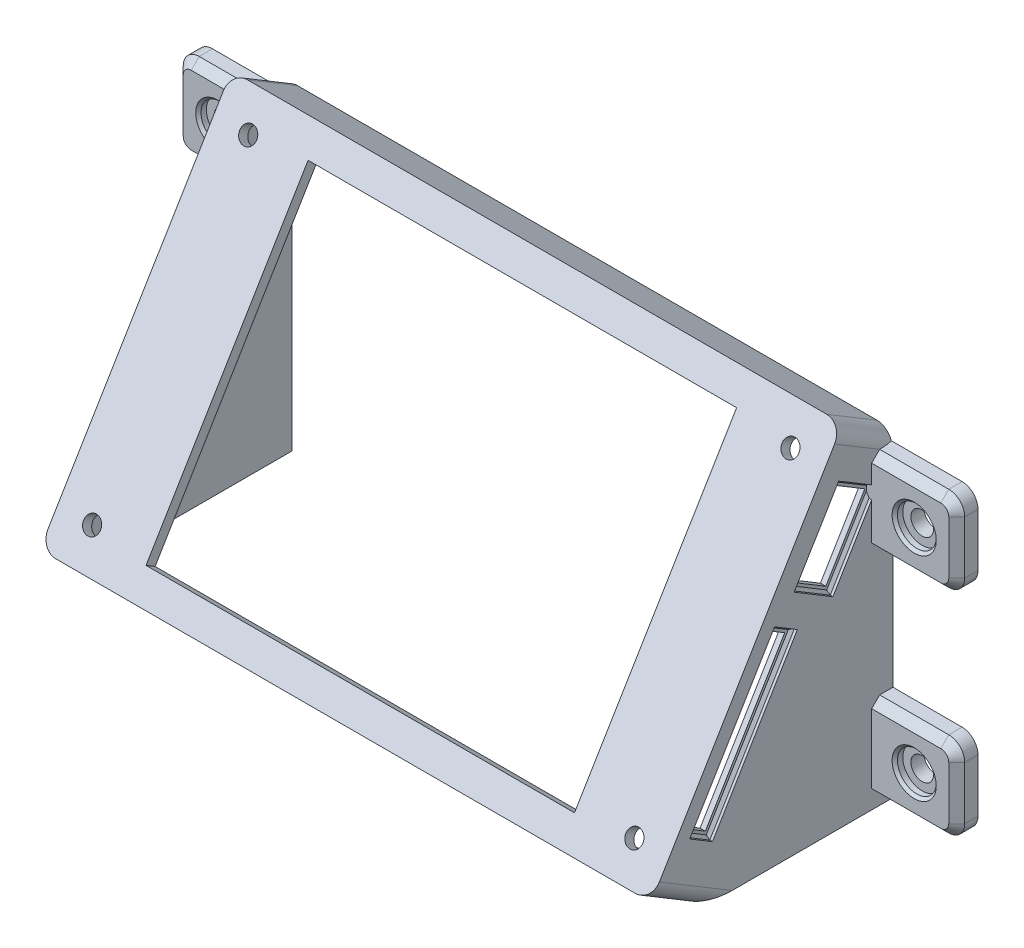
from build123d import *

# Parameters (mm, degrees)
BOSS_EXTRUDE1_DEPTH      = 115
SKETCH2_W                = 115
SKETCH2_H                = 70
BOSS_EXTRUDE2_DEPTH      = 11
FILLET1_R                = 3
SHELL1_T                 = -2
SKETCH3_R                = 1.6
CUT_EXTRUDE1_DEPTH       = 2
SKETCH4_W                = 80.6
SKETCH4_H                = 59.2
CUT_EXTRUDE2_DEPTH       = 2
CUT_EXTRUDE3_DEPTH       = 2
CUT_EXTRUDE4_DEPTH       = 1
CHAMFER3_SIZE            = 0.5
BOSS_EXTRUDE3_START      = -2
SKETCH7_W                = 4
SKETCH7_H                = 16
BOSS_EXTRUDE3_DEPTH      = 18
SKETCH8_R                = 2.125
CUT_EXTRUDE5_DEPTH       = 4
SKETCH9_R                = 3.65
CUT_EXTRUDE6_DEPTH       = 1.5
CHAMFER4_SIZE            = 0.5
FILLET2_R                = 3
CHAMFER4_OF_MIRROR1_SIZE = 0.5
FILLET2_OF_MIRROR1_R     = 3
CHAMFER5_SIZE            = 1.5


with BuildPart() as part:
    # Sketch1 → Boss-Extrude1 (new body)
    with BuildSketch(Plane(origin=(0, 0, 0), x_dir=(0, 0, -1), z_dir=(1, 0, 0))):
        Polygon((0, 0), (0, 60), (-36.055512755, 0), align=None)
    extrude(amount=BOSS_EXTRUDE1_DEPTH)

    # Sketch2 → Boss-Extrude2 (add)
    with BuildSketch(Plane(origin=(0, 15.918367347, 26.489764473), x_dir=(1, 0, 0), z_dir=(0, 0.515078754, 0.857142857))):
        with Locations((57.5, 16.428571429)):
            Rectangle(SKETCH2_W, SKETCH2_H)
    extrude(amount=BOSS_EXTRUDE2_DEPTH)

    # Fillet1
    fillet1_edges = [part.edges().sort_by_distance(p)[0] for p in [
        (0, 62.832933145, 4.714285714),
        (0, 2.832933145, 40.769798469),
        (115, 2.832933145, 40.769798469),
        (115, 62.832933145, 4.714285714),
    ]]
    fillet(fillet1_edges, radius=FILLET1_R)

    # Shell1
    shell1_openings = [part.faces().sort_by_distance(p)[0] for p in [
        (57.5, 39.074957911, 0),
        (57.5, 0, 22.497645419),
    ]]
    offset(amount=SHELL1_T, openings=shell1_openings, kind=Kind.INTERSECTION)

    # Sketch3 → Cut-Extrude1 (cut)
    with BuildSketch(Plane(origin=(0, 21.584233637, 35.918335901), x_dir=(1, 0, 0), z_dir=(0, 0.515078754, 0.857142857))):
        with Locations((6.5, 44.928571429)):
            Circle(SKETCH3_R)
        with Locations((6.5, -12.071428571)):
            Circle(SKETCH3_R)
        with Locations((108.5, -12.071428571)):
            Circle(SKETCH3_R)
        with Locations((108.5, 44.928571429)):
            Circle(SKETCH3_R)
    extrude(amount=-CUT_EXTRUDE1_DEPTH, mode=Mode.SUBTRACT)

    # Sketch4 → Cut-Extrude2 (cut)
    with BuildSketch(Plane(origin=(0, 21.584233637, 35.918335901), x_dir=(1, 0, 0), z_dir=(0, 0.515078754, 0.857142857))):
        with Locations((57.5, 16.428571429)):
            Rectangle(SKETCH4_W, SKETCH4_H)
    extrude(amount=-CUT_EXTRUDE2_DEPTH, mode=Mode.SUBTRACT)

    # Sketch5 → Cut-Extrude3 (cut)
    with BuildSketch(Plane(origin=(115, 0, 0), x_dir=(0, 0, -1), z_dir=(1, 0, 0))):
        Polygon((-36.861471556, 12.734320964), (-34.290042984, 11.189084703), (-19.352759129, 36.04622756), (-21.9241877, 37.591463821), align=None)
        Polygon((-17.207652396, 43.110512174), (-9.872930944, 55.31622646), (-4.301502372, 51.968214561), (-11.636223824, 39.762500275), align=None)
    extrude(amount=-CUT_EXTRUDE3_DEPTH, mode=Mode.SUBTRACT)

    # Sketch6 → Cut-Extrude4 (cut)
    with BuildSketch(Plane(origin=(115, 0, 0), x_dir=(0, 0, -1), z_dir=(1, 0, 0))):
        Polygon((-38.233693167, 12.39225686), (-33.947978881, 9.816863092), (-17.980537518, 36.388291664), (-22.266251804, 38.963685432), align=None)
        Polygon((-11.294159721, 38.390278664), (-2.929280762, 52.310278664), (-10.214995047, 56.68844807), (-18.579874006, 42.76844807), align=None)
    extrude(amount=-CUT_EXTRUDE4_DEPTH, mode=Mode.SUBTRACT)

    # Chamfer3
    chamfer3_edges = [part.edges().sort_by_distance(p)[0] for p in [
        (114, 40.579363367, 14.937016864),
        (114, 49.72844807, 14.397434527),
        (114, 54.499363367, 6.572137904),
        (114, 45.350278664, 7.111720241),
        (114, 25.677971146, 30.249972485),
        (114, 37.675988548, 20.123394661),
        (114, 23.102577378, 25.964258199),
        (114, 11.104559976, 36.090836024),
    ]]
    chamfer(chamfer3_edges, length=CHAMFER3_SIZE)

    # Sketch7 → Boss-Extrude3 (add)
    with BuildSketch(Plane(origin=(115, 0, 0), x_dir=(0, 0, -1), z_dir=(1, 0, 0)).offset(BOSS_EXTRUDE3_START)):
        with Locations((-2, 50)):
            Rectangle(SKETCH7_W, SKETCH7_H)
        with Locations((-2, 10)):
            Rectangle(SKETCH7_W, SKETCH7_H)
    boss_extrude3 = extrude(amount=BOSS_EXTRUDE3_DEPTH)

    # Sketch8 → Cut-Extrude5 (cut)
    with BuildSketch(Plane.XY.offset(4)):
        with Locations((123, 50)):
            Circle(SKETCH8_R)
        with Locations((123, 10)):
            Circle(SKETCH8_R)
    cut_extrude5 = extrude(amount=-CUT_EXTRUDE5_DEPTH, mode=Mode.SUBTRACT)

    # Sketch9 → Cut-Extrude6 (cut)
    with BuildSketch(Plane.XY.offset(4)):
        with Locations((123, 50)):
            Circle(SKETCH9_R)
        with Locations((123, 10)):
            Circle(SKETCH9_R)
    cut_extrude6 = extrude(amount=-CUT_EXTRUDE6_DEPTH, mode=Mode.SUBTRACT)

    # Chamfer4
    chamfer4_edges = [part.edges().sort_by_distance(p)[0] for p in [
        (119.35, 50, 4),
        (119.35, 10, 4),
    ]]
    chamfer(chamfer4_edges, length=CHAMFER4_SIZE)

    # Fillet2
    fillet2_edges = [part.edges().sort_by_distance(p)[0] for p in [
        (131, 58, 2),
        (131, 42, 2),
        (131, 18, 2),
        (131, 2, 2),
    ]]
    fillet(fillet2_edges, radius=FILLET2_R)

    # Mirror1: Boss-Extrude3, Cut-Extrude5, Cut-Extrude6 across plane
    add(boss_extrude3.mirror(Plane(origin=(57.5, 0, 0), x_dir=(0, 0, 1), z_dir=(1, 0, 0))))
    add(cut_extrude5.mirror(Plane(origin=(57.5, 0, 0), x_dir=(0, 0, 1), z_dir=(1, 0, 0))), mode=Mode.SUBTRACT)
    add(cut_extrude6.mirror(Plane(origin=(57.5, 0, 0), x_dir=(0, 0, 1), z_dir=(1, 0, 0))), mode=Mode.SUBTRACT)

    # Chamfer4 of Mirror1
    chamfer4_of_mirror1_edges = [part.edges().sort_by_distance(p)[0] for p in [
        (-4.35, 50, 4),
        (-4.35, 10, 4),
    ]]
    chamfer(chamfer4_of_mirror1_edges, length=CHAMFER4_OF_MIRROR1_SIZE)

    # Fillet2 of Mirror1
    fillet2_of_mirror1_edges = [part.edges().sort_by_distance(p)[0] for p in [
        (-16, 58, 2),
        (-16, 42, 2),
        (-16, 18, 2),
        (-16, 2, 2),
    ]]
    fillet(fillet2_of_mirror1_edges, radius=FILLET2_OF_MIRROR1_R)

    # Chamfer5
    chamfer5_edges = [part.edges().sort_by_distance(p)[0] for p in [
        (121.5, 42, 4),
        (121.5, 58, 4),
        (121.5, 2, 4),
        (121.5, 18, 4),
        (131, 10, 4),
        (130.121320344, 2.878679656, 4),
        (130.121320344, 17.121320344, 4),
        (131, 50, 4),
        (130.121320344, 42.878679656, 4),
        (130.121320344, 57.121320344, 4),
        (-6.5, 58, 4),
        (-6.5, 42, 4),
        (-6.5, 18, 4),
        (-6.5, 2, 4),
        (-16, 10, 4),
        (-15.121320344, 2.878679656, 4),
        (-15.121320344, 17.121320344, 4),
        (-16, 50, 4),
        (-15.121320344, 42.878679656, 4),
        (-15.121320344, 57.121320344, 4),
    ]]
    chamfer(chamfer5_edges, length=CHAMFER5_SIZE)


solid = part.part
